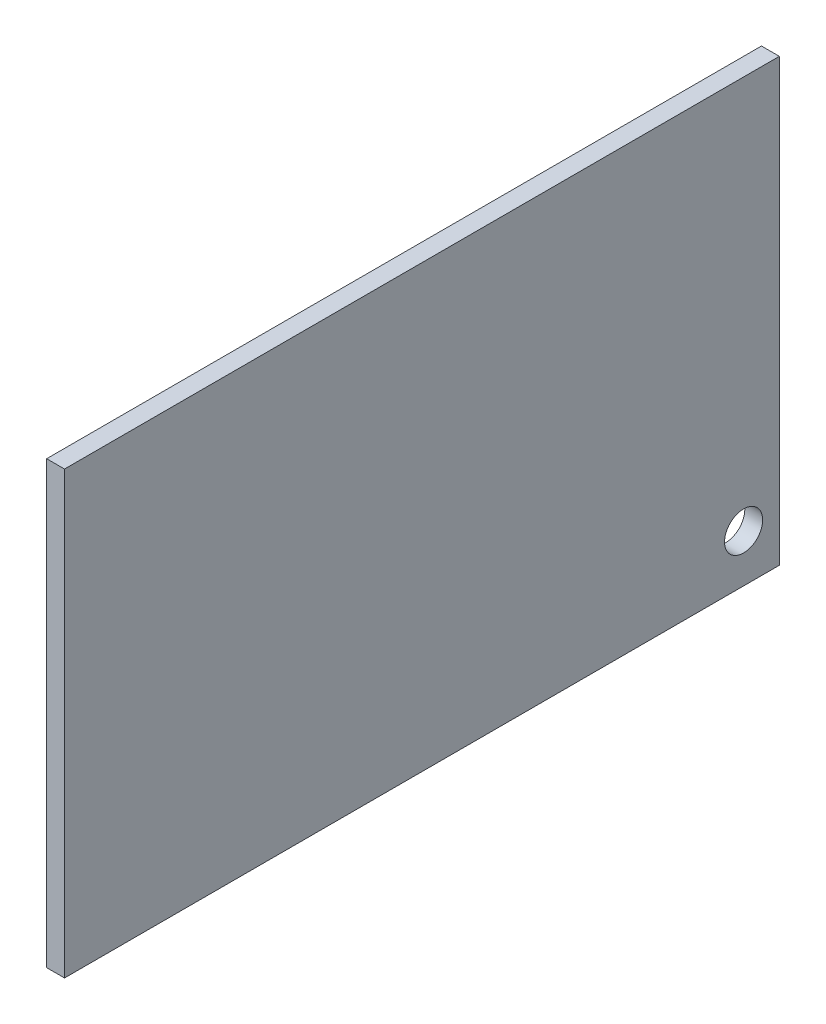
from build123d import *

# Parameters (mm, degrees)
SKETCH_1_W      = 60
SKETCH_1_H      = 37
SKETCH_1_R      = 1.6
EXTRUDE_1_DEPTH = 1.5


with BuildPart() as part:
    # Эскиз1 → Бобышка-Вытянуть1 (new body)
    with BuildSketch(Plane(origin=(0, 0, 0), x_dir=(0, 0, -1), z_dir=(1, 0, 0))):
        with Locations((30, 18.5)):
            Rectangle(SKETCH_1_W, SKETCH_1_H)
        with Locations((3, 4)):
            Circle(SKETCH_1_R, mode=Mode.SUBTRACT)
        with Locations((57, 4)):
            Circle(SKETCH_1_R, mode=Mode.SUBTRACT)
        with Locations((57, 34)):
            Circle(SKETCH_1_R, mode=Mode.SUBTRACT)
        with Locations((3, 34)):
            Circle(SKETCH_1_R, mode=Mode.SUBTRACT)
        with Locations((3, 34)):
            Circle(SKETCH_1_R)
        with Locations((3, 4)):
            Circle(SKETCH_1_R)
        with Locations((57, 34)):
            Circle(SKETCH_1_R)
    extrude(amount=EXTRUDE_1_DEPTH)


solid = part.part
